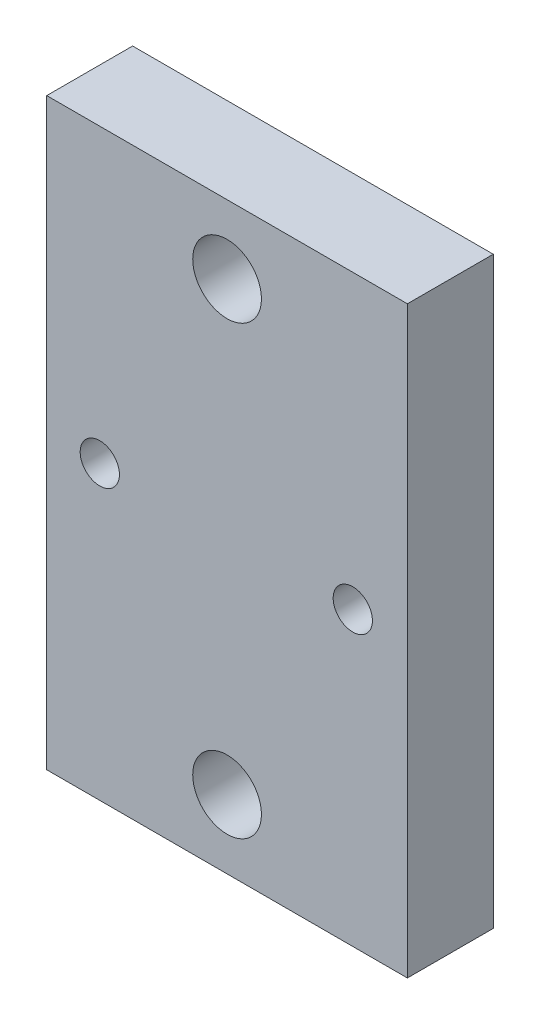
from build123d import *

# Parameters (mm, degrees)
SKETCH1_W           = 21
SKETCH1_H           = 34
BOSS_EXTRUDE1_DEPTH = 5
SKETCH2_R           = 1.143
CUT_EXTRUDE1_DEPTH  = 10
SKETCH3_R           = 2
CUT_EXTRUDE2_DEPTH  = 10


with BuildPart() as part:
    # Sketch1 → Boss-Extrude1 (new body)
    with BuildSketch(Plane.XY):
        Rectangle(SKETCH1_W, SKETCH1_H)
    extrude(amount=BOSS_EXTRUDE1_DEPTH)

    # Sketch2 → Cut-Extrude1 (cut)
    with BuildSketch(Plane(origin=(0, 0, 0), x_dir=(-1, 0, 0), z_dir=(0, 0, -1))):
        with Locations((7.411509934, 0)):
            Circle(SKETCH2_R)
        with Locations((-7.320490066, 0)):
            Circle(SKETCH2_R)
    extrude(amount=-CUT_EXTRUDE1_DEPTH, mode=Mode.SUBTRACT)

    # Sketch3 → Cut-Extrude2 (cut)
    with BuildSketch(Plane(origin=(0, 0, 0), x_dir=(-1, 0, 0), z_dir=(0, 0, -1))):
        with Locations((0, -13)):
            Circle(SKETCH3_R)
        with Locations((0, 13)):
            Circle(SKETCH3_R)
    extrude(amount=-CUT_EXTRUDE2_DEPTH, mode=Mode.SUBTRACT)


solid = part.part
